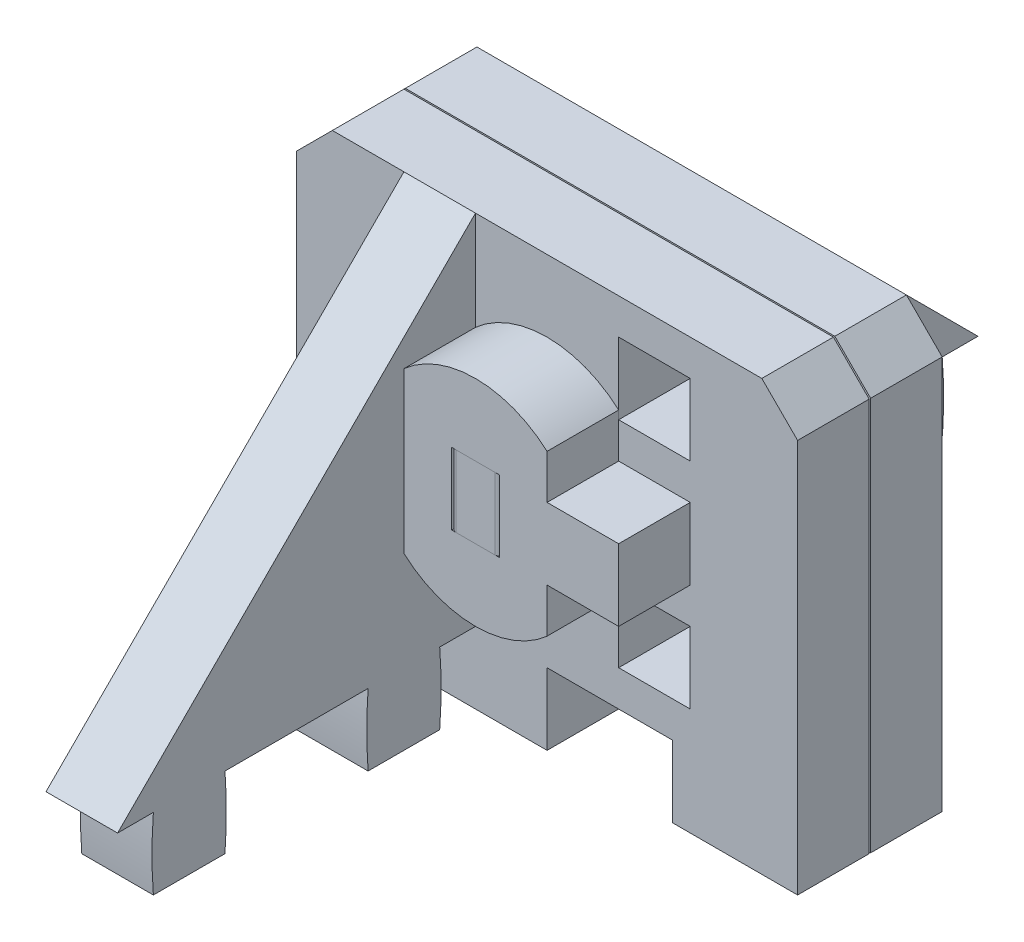
from build123d import *

# Parameters (mm, degrees)
SCHIZZO1_W                    = 21
SCHIZZO1_H                    = 21
SCHIZZO1_R                    = 2.121320344
SCHIZZO1_W_2                  = 3
SCHIZZO1_H_2                  = 3
ESTRUSIONE_ESTRUSIONE1_DEPTH  = 3
TAGLIO_ESTRUSIONE1_REACH      = 5
SCHIZZO6_W                    = 5.25
SCHIZZO6_H                    = 3
ESTRUSIONE_ESTRUSIONE2_DEPTH  = 3
ESTRUSIONE_ESTRUSIONE4_DEPTH  = 1.5
TAGLIO_ESTRUSIONE2_DEPTH      = 1
TAGLIO_ESTRUSIONE2_DEPTH_BACK = 22
SMUSSO1_SIZE                  = 1.5
SCHIZZO5_W                    = 2
SCHIZZO5_H                    = 3
ESTRUSIONE_ESTRUSIONE5_DEPTH  = 3
RACCORDO1_R                   = 0.2
RACCORDO2_R                   = 0.2


with BuildPart() as part:
    # Schizzo1 → Estrusione-Estrusione1 (new body)
    with BuildSketch(Plane.XY):
        Rectangle(SCHIZZO1_W, SCHIZZO1_H)
        Circle(SCHIZZO1_R, mode=Mode.SUBTRACT)
        with Locations((-4.5, 4.5)):
            Rectangle(SCHIZZO1_W_2, SCHIZZO1_H_2, mode=Mode.SUBTRACT)
        with Locations((-4.5, -4.5)):
            Rectangle(SCHIZZO1_W_2, SCHIZZO1_H_2, mode=Mode.SUBTRACT)
        with Locations((4.5, -4.5)):
            Rectangle(SCHIZZO1_W_2, SCHIZZO1_H_2, mode=Mode.SUBTRACT)
        with Locations((4.5, 4.5)):
            Rectangle(SCHIZZO1_W_2, SCHIZZO1_H_2, mode=Mode.SUBTRACT)
    extrude(amount=ESTRUSIONE_ESTRUSIONE1_DEPTH)

    # Schizzo6 → Taglio-Estrusione1 (cut, up to next)
    with BuildSketch(Plane.XY.offset(3), mode=Mode.PRIVATE) as taglio_estrusione1_sk1:
        with Locations((-7.875, -9)):
            Rectangle(SCHIZZO6_W, SCHIZZO6_H)
    taglio_estrusione1_tool1 = extrude(taglio_estrusione1_sk1.sketch, amount=-TAGLIO_ESTRUSIONE1_REACH, mode=Mode.PRIVATE) & part.part
    add(taglio_estrusione1_tool1.solids().sort_by_distance((-7.875, -9, 3))[0], mode=Mode.SUBTRACT)
    # Schizzo6 → Taglio-Estrusione1 (cut, up to next)
    with BuildSketch(Plane.XY.offset(3), mode=Mode.PRIVATE) as taglio_estrusione1_sk2:
        with Locations((2.625, -9)):
            Rectangle(SCHIZZO6_W, SCHIZZO6_H)
    taglio_estrusione1_tool2 = extrude(taglio_estrusione1_sk2.sketch, amount=-TAGLIO_ESTRUSIONE1_REACH, mode=Mode.PRIVATE) & part.part
    add(taglio_estrusione1_tool2.solids().sort_by_distance((2.625, -9, 3))[0], mode=Mode.SUBTRACT)


with BuildPart() as body_2:
    # Schizzo2 → Estrusione-Estrusione2 (new body)
    with BuildSketch(Plane(origin=(-6, 0, 0), x_dir=(0, 0, -1), z_dir=(1, 0, 0))):
        with BuildLine():
            Line((-3, 6), (-3, 3))
            ThreePointArc((-3, 3), (-1.5, 2.94), (0, 3))
            Line((0, 3), (0, 1.5))
            Line((0, 1.5), (3, 1.5))
            Line((3, 1.5), (3, -1.5))
            Line((3, -1.5), (0, -1.5))
            Line((0, -1.5), (0, -3))
            ThreePointArc((0, -3), (-1.5, -2.94), (-3, -3))
            Line((-3, -3), (-3, -6))
            ThreePointArc((-3, -6), (-1.5, -6.06), (0, -6))
            Line((0, -6), (0, -7.5))
            Line((0, -7.5), (1.5, -7.5))
            ThreePointArc((1.5, -7.5), (1.44, -9), (1.5, -10.5))
            Line((1.5, -10.5), (4.5, -10.5))
            ThreePointArc((4.5, -10.5), (4.56, -9), (4.5, -7.5))
            Line((4.5, -7.5), (10.5, -7.5))
            ThreePointArc((10.5, -7.5), (10.44, -9), (10.5, -10.5))
            Line((10.5, -10.5), (13.5, -10.5))
            ThreePointArc((13.5, -10.5), (13.56, -9), (13.5, -7.5))
            Line((13.5, -7.5), (15.75, -7.5))
            Line((15.75, -7.5), (15.75, -5.25))
            Line((15.75, -5.25), (2.25, 8.25))
            Line((2.25, 8.25), (0, 8.25))
            Line((0, 8.25), (0, 6))
            ThreePointArc((0, 6), (-1.5, 6.06), (-3, 6))
        make_face()
    extrude(amount=ESTRUSIONE_ESTRUSIONE2_DEPTH)


with BuildPart() as body_3:
    # Schizzo4 → Estrusione-Estrusione4 (new body, symmetric)
    with BuildSketch(Plane(origin=(0, 0, 0), x_dir=(0, 0, -1), z_dir=(0, 1, 0))):
        with BuildLine():
            Line((0, 1.5), (0, 2.598076211))
            Line((0, 2.598076211), (3, 2.598076211))
            Line((3, 2.598076211), (3, -2.598076211))
            Line((3, -2.598076211), (0, -2.598076211))
            Line((0, -2.598076211), (0, -1.5))
            Line((0, -1.5), (-6.06, -1.5))
            Line((-6.06, -1.5), (-6.06, -1))
            ThreePointArc((-6.06, -1), (-7.56, -1.06), (-9.06, -1))
            Line((-9.06, -1), (-9.06, 1))
            ThreePointArc((-9.06, 1), (-7.56, 1.06), (-6.06, 1))
            Line((-6.06, 1), (-6.06, 1.5))
            Line((-6.06, 1.5), (0, 1.5))
        make_face()
    extrude(amount=ESTRUSIONE_ESTRUSIONE4_DEPTH, both=True)

    # Raccordo1
    raccordo1_edges = [body_3.edges().sort_by_distance(p)[0] for p in [
        (1, 0, 9.06),
        (-1, 0, 9.06),
    ]]
    fillet(raccordo1_edges, radius=RACCORDO1_R)


with BuildPart() as taglio_estrusione2_tool:
    # Schizzo8 → Taglio-Estrusione2 (new body, two sides)
    with BuildSketch(Plane(origin=(10.5, 0, 0), x_dir=(0, 0, -1), z_dir=(1, 0, 0))) as taglio_estrusione2_sk:
        Polygon((0, 7.5), (18, -10.5), (18, -7.5), (0, 10.5), (-3, 10.5), (-3, 7.5), align=None)
    extrude(amount=TAGLIO_ESTRUSIONE2_DEPTH)
    extrude(taglio_estrusione2_sk.sketch, amount=-TAGLIO_ESTRUSIONE2_DEPTH_BACK)


with BuildPart() as part_1:
    add(part.part)

    # Taglio-Estrusione2: cut by taglio_estrusione2_tool
    add(taglio_estrusione2_tool.part, mode=Mode.SUBTRACT)

    # Smusso1
    smusso1_edges = [part_1.edges().sort_by_distance(p)[0] for p in [
        (10.5, 7.5, 1.5),
        (-10.5, 7.5, 1.5),
    ]]
    chamfer(smusso1_edges, length=SMUSSO1_SIZE)


with BuildPart() as body_2_1:
    add(body_2.part)

    # Taglio-Estrusione2: cut by taglio_estrusione2_tool
    add(taglio_estrusione2_tool.part, mode=Mode.SUBTRACT)


with BuildPart() as body_4:
    # Schizzo5 → Estrusione-Estrusione5 (new body)
    with BuildSketch(Plane.XY.offset(6.06)):
        with BuildLine():
            Line((-3, -3.354101966), (-3, -1.5))
            Line((-3, -1.5), (-6, -1.5))
            Line((-6, -1.5), (-6, 1.5))
            Line((-6, 1.5), (-3, 1.5))
            Line((-3, 1.5), (-3, 3.354101966))
            ThreePointArc((-3, 3.354101966), (0, 4.5), (3, 3.354101966))
            Line((3, 3.354101966), (3, 1.5))
            Line((3, 1.5), (6, 1.5))
            Line((6, 1.5), (6, -1.5))
            Line((6, -1.5), (3, -1.5))
            Line((3, -1.5), (3, -3.354101966))
            ThreePointArc((3, -3.354101966), (0, -4.5), (-3, -3.354101966))
        make_face()
        Rectangle(SCHIZZO5_W, SCHIZZO5_H, mode=Mode.SUBTRACT)
    extrude(amount=ESTRUSIONE_ESTRUSIONE5_DEPTH)


with BuildPart() as body_5:
    # Specchia1: mirrored copy
    add(part_1.part.mirror(Plane(origin=(0, 0, 3.03), x_dir=(1, 0, 0), z_dir=(0, 0, -1))))


with BuildPart() as body_6:
    # Specchia1 2: mirrored copy
    add(body_2_1.part.mirror(Plane(origin=(0, 0, 3.03), x_dir=(1, 0, 0), z_dir=(0, 0, -1))))


with BuildPart() as body_2_2:
    add(body_2_1.part)

    # Raccordo2
    raccordo2_edges = [body_2_2.edges().sort_by_distance(p)[0] for p in [
        (-4.5, -10.5, -13.5),
        (-4.5, -10.5, -10.5),
        (-4.5, -10.5, -4.5),
        (-4.5, -10.5, -1.5),
        (-4.5, -6, 3),
        (-4.5, -3, 3),
        (-4.5, 3, 3),
        (-4.5, 6, 3),
    ]]
    fillet(raccordo2_edges, radius=RACCORDO2_R)


solid = Compound([body_3.part, part_1.part, body_4.part, body_5.part, body_6.part, body_2_2.part])
